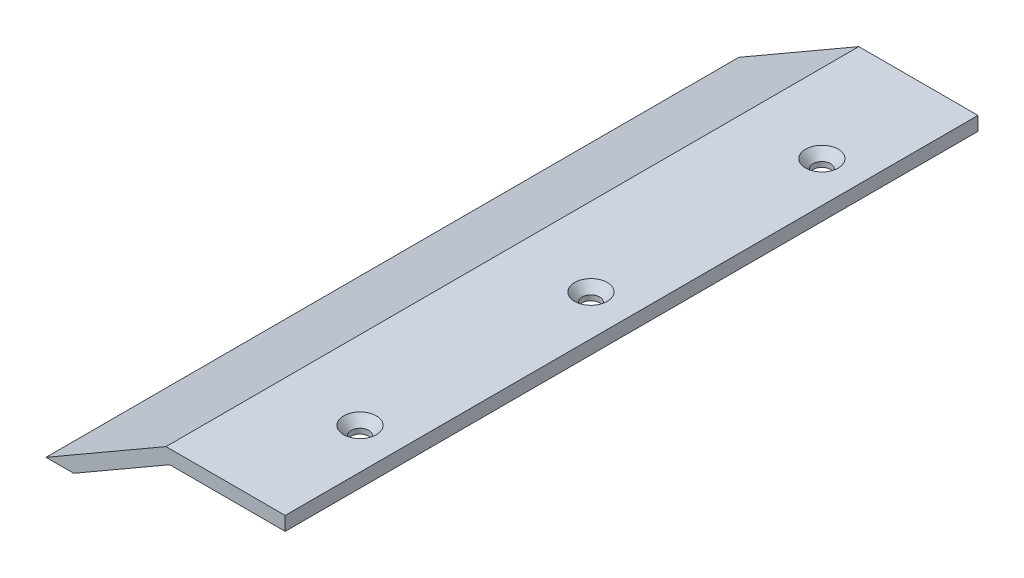
from build123d import *

# Parameters (mm, degrees)
SALIENTE_EXTRUIR1_DEPTH                              = 75
AVELLANADO_PARA_TORNILLO_CON_CABEZA_OVAL_D           = 3.7973
AVELLANADO_PARA_TORNILLO_CON_CABEZA_OVAL_DEPTH       = 20
AVELLANADO_PARA_TORNILLO_CON_CABEZA_OVAL_CSINK_D     = 7.0866
AVELLANADO_PARA_TORNILLO_CON_CABEZA_OVAL_CSINK_ANGLE = 82
AVELLANADO_PARA_TORNILLO_CON_CABEZA_OVAL_TIP         = 1.140824014


with BuildPart() as part:
    # Croquis1 → Saliente-Extruir1 (new body, symmetric)
    with BuildSketch(Plane.XY):
        Polygon((25, 0), (25, 3), (-0.803847577, 3), (-26.784609691, -12), (-20.784609691, -12), (0, 0), align=None)
    extrude(amount=SALIENTE_EXTRUIR1_DEPTH, both=True)

    # Avellanado para tornillo con cabeza ovalada de #61
    with Locations(Plane(origin=(16.2, 3, -50), x_dir=(1, 0, 0), z_dir=(0, 1, 0))):
        with Locations((0, 0), (0, -50), (0, -100)):
            CounterSinkHole(AVELLANADO_PARA_TORNILLO_CON_CABEZA_OVAL_D / 2, AVELLANADO_PARA_TORNILLO_CON_CABEZA_OVAL_CSINK_D / 2, depth=AVELLANADO_PARA_TORNILLO_CON_CABEZA_OVAL_DEPTH, counter_sink_angle=AVELLANADO_PARA_TORNILLO_CON_CABEZA_OVAL_CSINK_ANGLE)
            with Locations((0, 0, -(AVELLANADO_PARA_TORNILLO_CON_CABEZA_OVAL_DEPTH + AVELLANADO_PARA_TORNILLO_CON_CABEZA_OVAL_TIP / 2))):  # 118° drill point
                Cone(0, AVELLANADO_PARA_TORNILLO_CON_CABEZA_OVAL_D / 2, AVELLANADO_PARA_TORNILLO_CON_CABEZA_OVAL_TIP, mode=Mode.SUBTRACT)


solid = part.part
